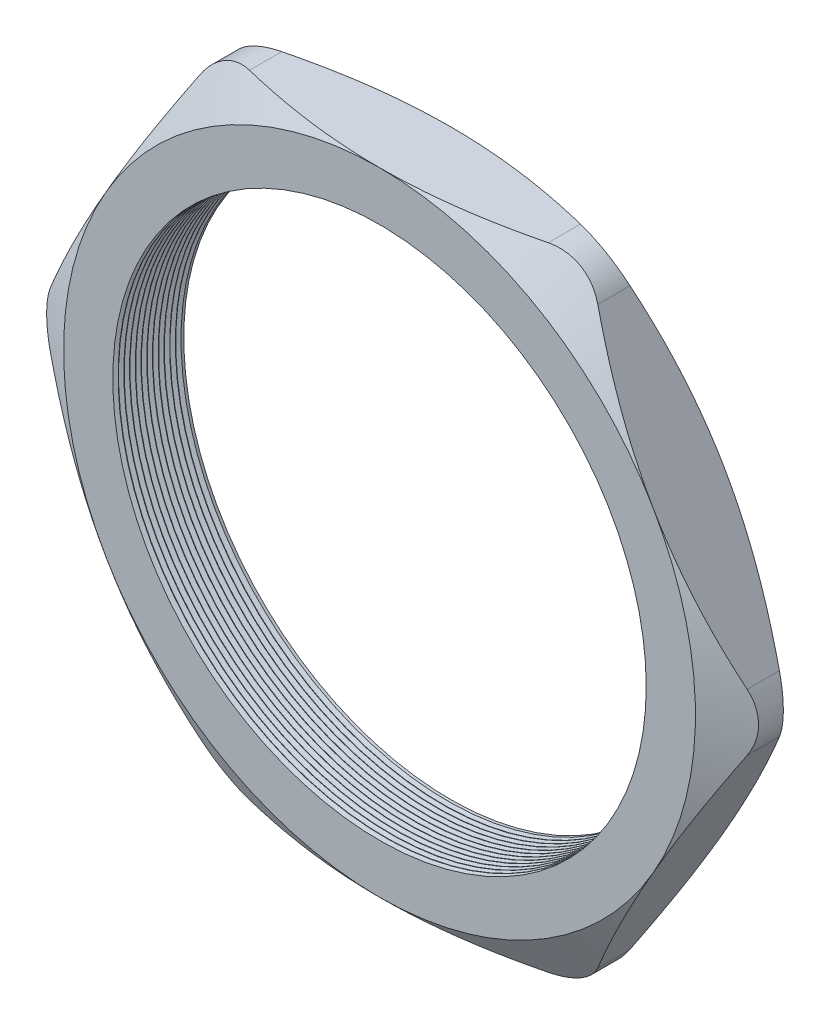
from build123d import *

# Parameters (mm, degrees)
SKETCH1_R          = 29.591
EXTRUDE1_DEPTH     = 7.874
SKETCH2_OUTSIDE_W  = 135.166
SKETCH2_OUTSIDE_H  = 124.32
SKETCH2_OUTSIDE_R  = 35.052
CUT_EXTRUDE1_DEPTH = 8.874
CUT_EXTRUDE1_DRAFT = -60
SKETCH3_OUTSIDE_W  = 135.166
SKETCH3_OUTSIDE_H  = 124.32
SKETCH3_OUTSIDE_R  = 35.052
CUT_EXTRUDE2_DEPTH = 8.874
CUT_EXTRUDE2_DRAFT = -60
FILLET1_R          = 6.35
LPATTERN1_COUNT    = 12
LPATTERN1_PITCH    = 0.635


with BuildPart() as part:
    # Sketch1 → Extrude1 (new body)
    with BuildSketch(Plane.XY):
        Polygon((-40.474563271, 0), (-20.237281636, -35.052), (20.237281636, -35.052), (40.474563271, 0), (20.237281636, 35.052), (-20.237281636, 35.052), align=None)
        Circle(SKETCH1_R, mode=Mode.SUBTRACT)
    extrude(amount=EXTRUDE1_DEPTH)


with BuildPart() as cut_extrude1_tool:
    # Sketch2 outside → Cut-Extrude1 (with draft: the straight prism first)
    with BuildSketch(Plane.XY.offset(7.874)):
        Rectangle(SKETCH2_OUTSIDE_W, SKETCH2_OUTSIDE_H)
        Circle(SKETCH2_OUTSIDE_R, mode=Mode.SUBTRACT)
    extrude(amount=-CUT_EXTRUDE1_DEPTH)
    # Cut-Extrude1: the draft: its side faces are tilted about the plane it starts from
    cut_extrude1_sides = [cut_extrude1_tool.faces().sort_by_distance(p)[0] for p in [
        (0, -62.16, 3.437),
        (67.583, 0, 3.437),
        (0, 62.16, 3.437),
        (-67.583, 0, 3.437),
        (-35.052, 0, 3.437),
    ]]
    draft(cut_extrude1_sides, Plane.XY.offset(7.874), CUT_EXTRUDE1_DRAFT)


with BuildPart() as part_1:
    add(part.part)

    # Cut-Extrude1: cut by cut_extrude1_tool
    add(cut_extrude1_tool.part, mode=Mode.SUBTRACT)


with BuildPart() as cut_extrude2_tool:
    # Sketch3 outside → Cut-Extrude2 (with draft: the straight prism first)
    with BuildSketch(Plane(origin=(0, 0, 0), x_dir=(-1, 0, 0), z_dir=(0, 0, -1))):
        Rectangle(SKETCH3_OUTSIDE_W, SKETCH3_OUTSIDE_H)
        Circle(SKETCH3_OUTSIDE_R, mode=Mode.SUBTRACT)
    extrude(amount=-CUT_EXTRUDE2_DEPTH)
    # Cut-Extrude2: the draft: its side faces are tilted about the plane it starts from
    cut_extrude2_sides = [cut_extrude2_tool.faces().sort_by_distance(p)[0] for p in [
        (0, -62.16, 4.437),
        (-67.583, 0, 4.437),
        (0, 62.16, 4.437),
        (67.583, 0, 4.437),
        (35.052, 0, 4.437),
    ]]
    draft(cut_extrude2_sides, Plane(origin=(0, 0, 0), x_dir=(-1, 0, 0), z_dir=(0, 0, -1)), CUT_EXTRUDE2_DRAFT)


with BuildPart() as part_2:
    add(part_1.part)

    # Cut-Extrude2: cut by cut_extrude2_tool
    add(cut_extrude2_tool.part, mode=Mode.SUBTRACT)

    # Fillet1
    fillet1_edges = [part_2.edges().sort_by_distance(p)[0] for p in [
        (40.474563271, 0, 3.937),
        (20.237281636, -35.052, 3.937),
        (-20.237281636, -35.052, 3.937),
        (-40.474563271, 0, 3.937),
        (-20.237281636, 35.052, 3.937),
        (20.237281636, 35.052, 3.937),
    ]]
    fillet(fillet1_edges, radius=FILLET1_R)

    # Sketch4 → Cut-Revolve1 (revolve, cut)
    with BuildSketch(Plane(origin=(0, 0, 0), x_dir=(1, 0, 0), z_dir=(0, 1, 0)), mode=Mode.PRIVATE) as cut_revolve1_sk:
        Polygon((-29.591, -7.874), (-29.591, -7.287412127), (-30.099, -7.580706063), align=None)
    cut_revolve1 = revolve(cut_revolve1_sk.sketch.rotate(Axis((0, 0, 0), (0, 0, 1)), 180), axis=Axis((0, 0, 0), (0, 0, 1)), mode=Mode.SUBTRACT)  # turned: the seam where the file's is

    # LPattern1: Cut-Revolve1 ×12
    with Locations(*[(0, 0, -i * LPATTERN1_PITCH) for i in range(1, LPATTERN1_COUNT)]):
        add(cut_revolve1, mode=Mode.SUBTRACT)


solid = part_2.part
